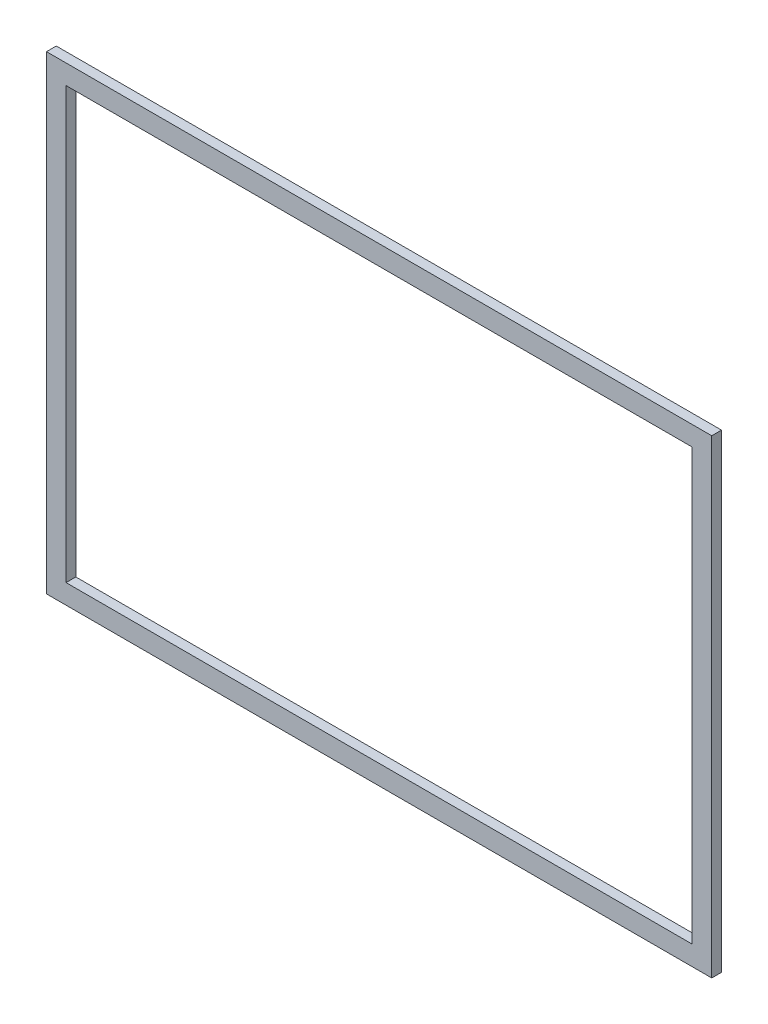
from build123d import *

# Parameters (mm, degrees)
ESQUISSE1_W        = 680
ESQUISSE1_H        = 480
ESQUISSE1_W_2      = 640
ESQUISSE1_H_2      = 440
BOSS_EXTRU_1_DEPTH = 10


with BuildPart() as part:
    # Esquisse1 → Boss.-Extru.1 (new body)
    with BuildSketch(Plane.XY):
        with Locations((-340, 240)):
            Rectangle(ESQUISSE1_W, ESQUISSE1_H)
        with Locations((-340, 240)):
            Rectangle(ESQUISSE1_W_2, ESQUISSE1_H_2, mode=Mode.SUBTRACT)
    extrude(amount=BOSS_EXTRU_1_DEPTH)


solid = part.part
